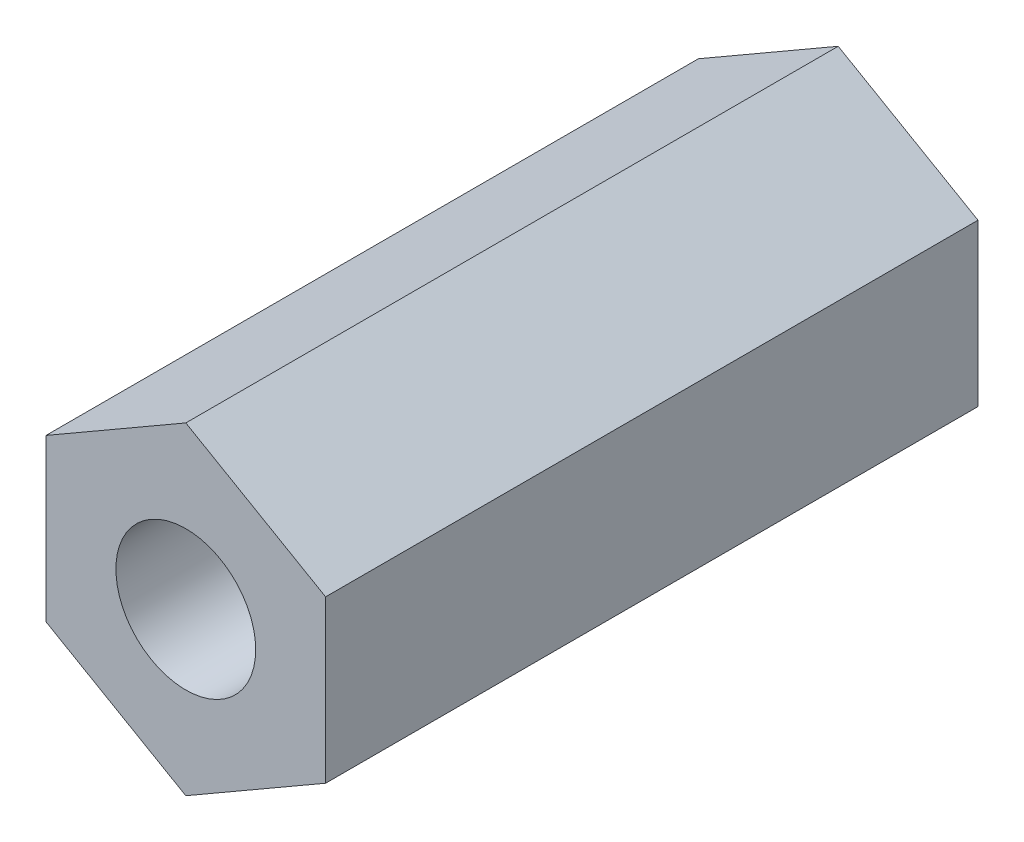
from build123d import *

# Parameters (mm, degrees)
SKETCH1_R           = 1.5
EXTRUDE1_DEPTH      = 7
EXTRUDE1_DEPTH_BACK = 7


with BuildPart() as part:
    # Sketch1 → Extrude1 (new body, two sides)
    with BuildSketch(Plane.XY) as extrude1_sk:
        Polygon((0, 3.464101615), (-3, 1.732050808), (-3, -1.732050808), (0, -3.464101615), (3, -1.732050808), (3, 1.732050808), align=None)
        Circle(SKETCH1_R, mode=Mode.SUBTRACT)
    extrude(amount=EXTRUDE1_DEPTH)
    extrude(extrude1_sk.sketch, amount=-EXTRUDE1_DEPTH_BACK)


solid = part.part
